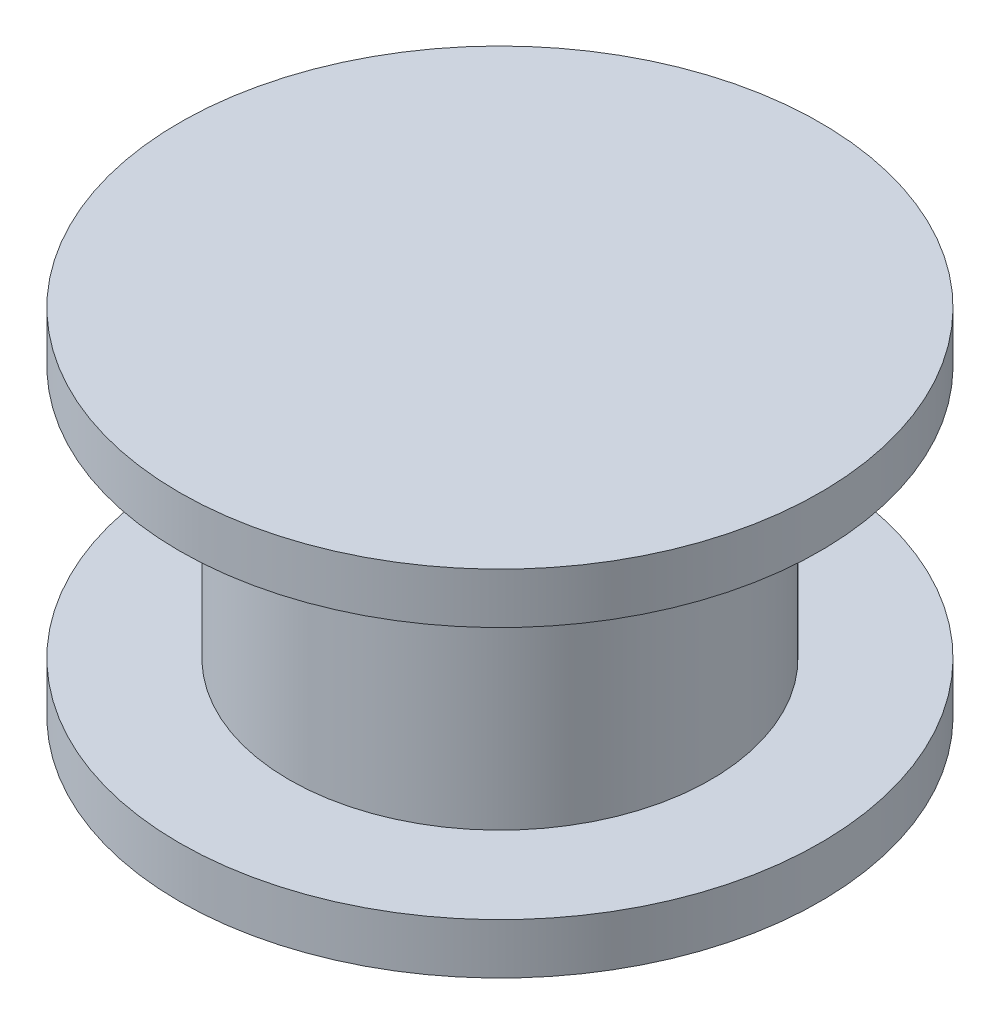
from build123d import *

# Parameters (mm, degrees)
SKETCH1_R           = 9.5
BOSS_EXTRUDE1_DEPTH = 1.5
SKETCH2_R           = 6.25
BOSS_EXTRUDE2_DEPTH = 7.5
SKETCH4_R           = 9.5
BOSS_EXTRUDE4_DEPTH = 1.5


with BuildPart() as part:
    # Sketch1 → Boss-Extrude1 (new body)
    with BuildSketch(Plane(origin=(0, 0, 0), x_dir=(1, 0, 0), z_dir=(0, 1, 0))):
        Circle(SKETCH1_R)
    extrude(amount=BOSS_EXTRUDE1_DEPTH)

    # Sketch2 → Boss-Extrude2 (add)
    with BuildSketch(Plane(origin=(0, 1.5, 0), x_dir=(1, 0, 0), z_dir=(0, 1, 0))):
        Circle(SKETCH2_R)
    extrude(amount=BOSS_EXTRUDE2_DEPTH)

    # Sketch4 → Boss-Extrude4 (add)
    with BuildSketch(Plane(origin=(0, 9, 0), x_dir=(1, 0, 0), z_dir=(0, 1, 0))):
        Circle(SKETCH4_R)
    extrude(amount=BOSS_EXTRUDE4_DEPTH)


solid = part.part
